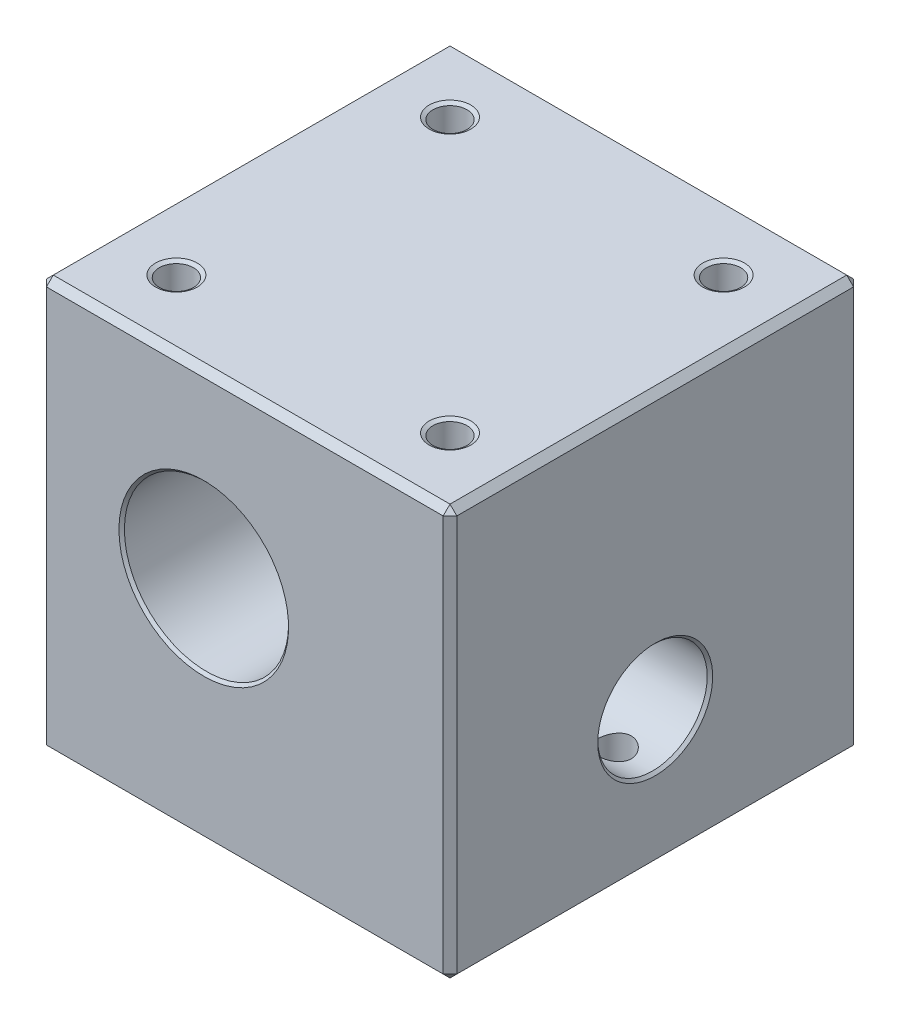
from build123d import *

# Parameters (mm, degrees)
SCHIZZO1_W                      = 30
SCHIZZO1_H                      = 30
SCHIZZO1_R                      = 6
ESTRUSIONE_ESTRUSIONE1_DEPTH    = 30
F_8_0_8_DIAMETER_HOLE1_D        = 8
F_8_0_8_DIAMETER_HOLE1_DEPTH    = 13.5
F_8_0_8_DIAMETER_HOLE1_TIP      = 2.403442476
FORO_FILETTATO_M3_1_AT_2_COUNT  = 2
FORO_FILETTATO_M3_1_AT_2_PITCH  = 20
FORO_FILETTATO_M3_2_D           = 2.5
FORO_FILETTATO_M3_2_DEPTH       = 8.5
FORO_FILETTATO_M3_2_CSINK_D     = 3.05
FORO_FILETTATO_M3_2_CSINK_ANGLE = 120
FORO_FILETTATO_M3_2_TIP         = 0.751075774
CHAMFER1_SIZE                   = 0.5
CHAMFER2_SIZE                   = 0.2


with BuildPart() as part:
    # Schizzo1 → Estrusione-Estrusione1 (new body)
    with BuildSketch(Plane.XY):
        with Locations((15, 15)):
            Rectangle(SCHIZZO1_W, SCHIZZO1_H)
        with Locations((12, 16.8)):
            Circle(SCHIZZO1_R, mode=Mode.SUBTRACT)
    extrude(amount=ESTRUSIONE_ESTRUSIONE1_DEPTH)

    # Ø8.0 (8) Diameter Hole1
    with Locations(Plane(origin=(30, 0, 0), x_dir=(0, 0, -1), z_dir=(1, 0, 0))):
        with Locations((-15, 10)):
            Hole(F_8_0_8_DIAMETER_HOLE1_D / 2, depth=F_8_0_8_DIAMETER_HOLE1_DEPTH)
            with Locations((0, 0, -(F_8_0_8_DIAMETER_HOLE1_DEPTH + F_8_0_8_DIAMETER_HOLE1_TIP / 2))):  # 118° drill point
                Cone(0, F_8_0_8_DIAMETER_HOLE1_D / 2, F_8_0_8_DIAMETER_HOLE1_TIP, mode=Mode.SUBTRACT)

    # Schizzo7 → Foro filettato M3-1 (revolve, cut)
    with BuildSketch(Plane(origin=(5, 30, 25), x_dir=(0, 0, 1), z_dir=(1, 0, 0))):
        Polygon((0, 0), (0, 9.251075774), (1.25, 8.5), (1.25, 0.158771324), (1.525, 0), align=None)
    foro_filettato_m3_1 = revolve(axis=Axis((5, 36.35, 25), (0, -1, 0)), mode=Mode.SUBTRACT)

    # Foro filettato M3-1 at 2: Foro filettato M3-1 ×2
    with Locations(*[(i * FORO_FILETTATO_M3_1_AT_2_PITCH, 0, 0) for i in range(1, FORO_FILETTATO_M3_1_AT_2_COUNT)]):
        add(foro_filettato_m3_1, mode=Mode.SUBTRACT)

    # Specchia1: Foro filettato M3-1 across plane
    add(foro_filettato_m3_1.mirror(Plane.XY.offset(15)), mode=Mode.SUBTRACT)

    # Specchia1 copy 1 sketch → Specchia1 copy 1 (revolve, cut)
    with BuildSketch(Plane(origin=(25, 30, 5), x_dir=(0, 0, -1), z_dir=(1, 0, 0))):
        Polygon((0, 0), (0, -9.251075774), (1.25, -8.5), (1.25, -0.158771324), (1.525, 0), align=None)
    revolve(axis=Axis((25, 36.35, 5), (0, 1, 0)), mode=Mode.SUBTRACT)

    # Foro filettato M3-2
    with Locations(Plane(origin=(0, 0, 0), x_dir=(-1, 0, 0), z_dir=(0, -1, 0))):
        with Locations((-27, -15)):
            CounterSinkHole(FORO_FILETTATO_M3_2_D / 2, FORO_FILETTATO_M3_2_CSINK_D / 2, depth=FORO_FILETTATO_M3_2_DEPTH, counter_sink_angle=FORO_FILETTATO_M3_2_CSINK_ANGLE)
            with Locations((0, 0, -(FORO_FILETTATO_M3_2_DEPTH + FORO_FILETTATO_M3_2_TIP / 2))):  # 118° drill point
                Cone(0, FORO_FILETTATO_M3_2_D / 2, FORO_FILETTATO_M3_2_TIP, mode=Mode.SUBTRACT)

    # Chamfer1
    chamfer1_edges = [part.edges().sort_by_distance(p)[0] for p in [
        (30, 15, 30),
        (15, 30, 30),
        (0, 15, 30),
        (15, 30, 0),
        (30, 15, 0),
        (15, 0, 0),
        (0, 15, 0),
        (15, 0, 30),
        (0, 30, 15),
        (30, 30, 15),
        (30, 0, 15),
        (0, 0, 15),
    ]]
    chamfer(chamfer1_edges, length=CHAMFER1_SIZE)

    # Chamfer2
    chamfer2_edges = [part.edges().sort_by_distance(p)[0] for p in [
        (6, 16.8, 0),
        (6, 16.8, 30),
        (30, 10, 11),
    ]]
    chamfer(chamfer2_edges, length=CHAMFER2_SIZE)


solid = part.part
